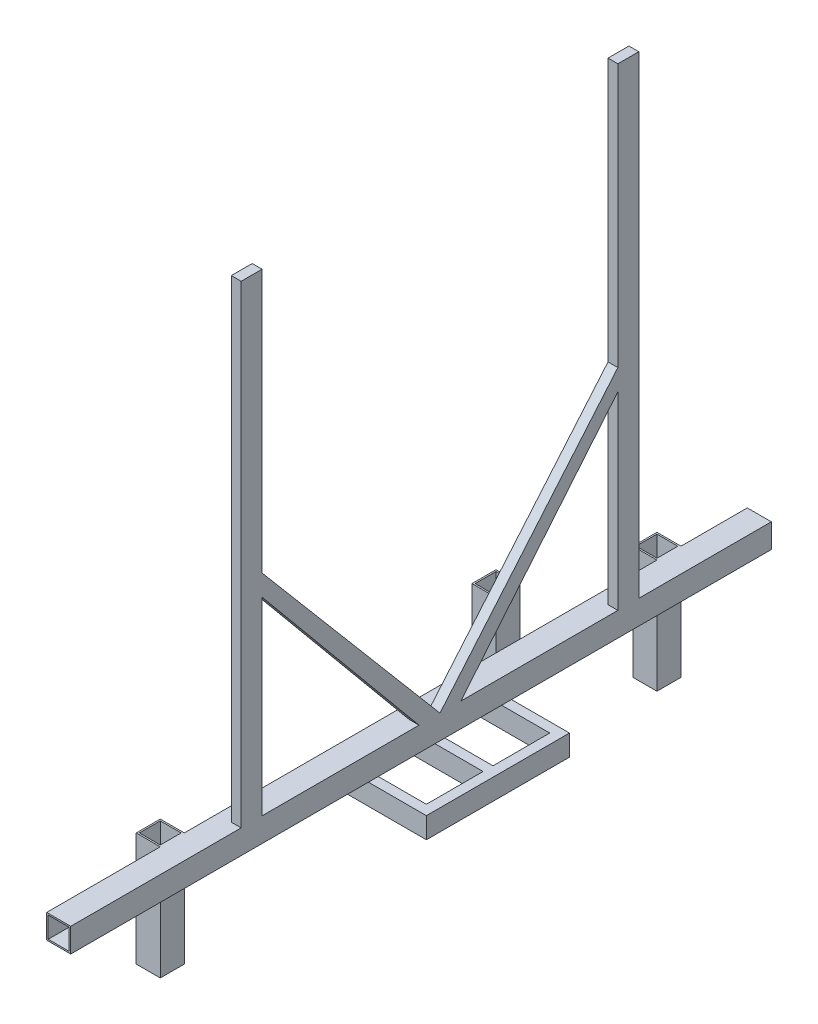
from build123d import *

# Parameters (mm, degrees)
SKETCH1_W                = 25.4
SKETCH1_H                = 25.4
SKETCH1_W_2              = 22.098
SKETCH1_H_2              = 22.098
BOSS_EXTRUDE1_DEPTH      = 370
SKETCH2_W                = 10.414
SKETCH2_H                = 22.098
BOSS_EXTRUDE2_DEPTH      = 500
SKETCH11_W               = 76.2
SKETCH11_H               = 10.414
BOSS_EXTRUDE3_DEPTH      = 22.098
SKETCH13_W               = 151.13
SKETCH13_H               = 22.098
BOSS_EXTRUDE4_DEPTH      = 10.414
SKETCH14_W               = 25.4
SKETCH14_H               = 25.4
SKETCH14_W_2             = 22.098
SKETCH14_H_2             = 22.098
BOSS_EXTRUDE5_DEPTH      = 120
BOSS_EXTRUDE6_DEPTH      = 50.8
BOSS_EXTRUDE6_DEPTH_BACK = 25.4
SKETCH15_W               = 25.4
SKETCH15_H               = 25.4
SKETCH15_W_2             = 22.098
SKETCH15_H_2             = 22.098


with BuildPart() as part:
    # Sketch1 → Boss-Extrude1 (new, symmetric)
    with BuildSketch(Plane.XY):
        Rectangle(SKETCH1_W, SKETCH1_H)
        Rectangle(SKETCH1_W_2, SKETCH1_H_2, mode=Mode.SUBTRACT)
    extrude(amount=BOSS_EXTRUDE1_DEPTH, both=True)

    # Sketch2 → Boss-Extrude2 (add)
    with BuildSketch(Plane(origin=(0, 12.7, 0), x_dir=(1, 0, 0), z_dir=(0, 1, 0))):
        with Locations((7.493, -178.951)):
            Rectangle(SKETCH2_W, SKETCH2_H)
        with Locations((7.493, 218.951)):
            Rectangle(SKETCH2_W, SKETCH2_H)
    extrude(amount=BOSS_EXTRUDE2_DEPTH)

    # Sketch3 → Loft3 section 0
    with BuildSketch(Plane(origin=(0, 0, 167.902), x_dir=(-1, 0, 0), z_dir=(0, 0, -1))):
        with BuildLine():
            Line((-2.286, 234.798), (-12.7, 234.798))
            Line((-12.7, 234.798), (-12.7, 212.7))
            Line((-12.7, 212.7), (-2.286, 212.7))
            Line((-2.286, 212.7), (-2.286, 234.798))
        make_face()
    # Sketch4 → Loft3 section 1
    with BuildSketch(Plane(origin=(0, 12.7, 0), x_dir=(1, 0, 0), z_dir=(0, 1, 0))):
        with BuildLine():
            Line((2.286, 20), (12.7, 20))
            Line((12.7, 20), (12.7, -2.098))
            Line((12.7, -2.098), (2.286, -2.098))
            Line((2.286, -2.098), (2.286, 20))
        make_face()
    loft3 = loft()

    # Mirror2: Loft3 across plane
    add(loft3.mirror(Plane.XY.offset(-20)))

    # Sketch11 → Boss-Extrude3 (add)
    with BuildSketch(Plane.XZ.offset(12.7)):
        with Locations((25.4, -20)):
            Rectangle(SKETCH11_W, SKETCH11_H)
        with Locations((25.4, 50.358)):
            Rectangle(SKETCH11_W, SKETCH11_H)
        with Locations((25.4, -90.358)):
            Rectangle(SKETCH11_W, SKETCH11_H)
    extrude(amount=BOSS_EXTRUDE3_DEPTH)

    # Sketch13 → Boss-Extrude4 (add)
    with BuildSketch(Plane(origin=(63.5, 0, 0), x_dir=(0, 0, -1), z_dir=(1, 0, 0))):
        with Locations((20, -23.749)):
            Rectangle(SKETCH13_W, SKETCH13_H)
    extrude(amount=BOSS_EXTRUDE4_DEPTH)

    # Sketch14 → Boss-Extrude5 (add)
    # profile 1 of 2: a face of its own
    with BuildSketch(Plane(origin=(0, 12.7, 0), x_dir=(1, 0, 0), z_dir=(0, 1, 0))):
        with Locations((-25.4, -237.3)):
            Rectangle(SKETCH14_W, SKETCH14_H)
        with Locations((-25.4, -237.3)):
            Rectangle(SKETCH14_W_2, SKETCH14_H_2, mode=Mode.SUBTRACT)
    # profile 2 of 2: a face of its own
    with BuildSketch(Plane(origin=(0, 12.7, 0), x_dir=(1, 0, 0), z_dir=(0, 1, 0))):
        with Locations((-25.4, 287.3)):
            Rectangle(SKETCH14_W, SKETCH14_H)
        with Locations((-25.4, 287.3)):
            Rectangle(SKETCH14_W_2, SKETCH14_H_2, mode=Mode.SUBTRACT)
    extrude(amount=-BOSS_EXTRUDE5_DEPTH)


with BuildPart() as body_2:
    # Sketch15 → Boss-Extrude6 (new, two sides: drawn at the far end of the back side and taken through both)
    with BuildSketch(Plane(origin=(0, 12.7, 0), x_dir=(1, 0, 0), z_dir=(0, 1, 0)).offset(-BOSS_EXTRUDE6_DEPTH_BACK)):
        with Locations((-25.4, 117.3)):
            Rectangle(SKETCH15_W, SKETCH15_H)
        with Locations((-25.4, 117.3)):
            Rectangle(SKETCH15_W_2, SKETCH15_H_2, mode=Mode.SUBTRACT)
    extrude(amount=BOSS_EXTRUDE6_DEPTH + BOSS_EXTRUDE6_DEPTH_BACK)


solid = Compound([part.part, body_2.part])
